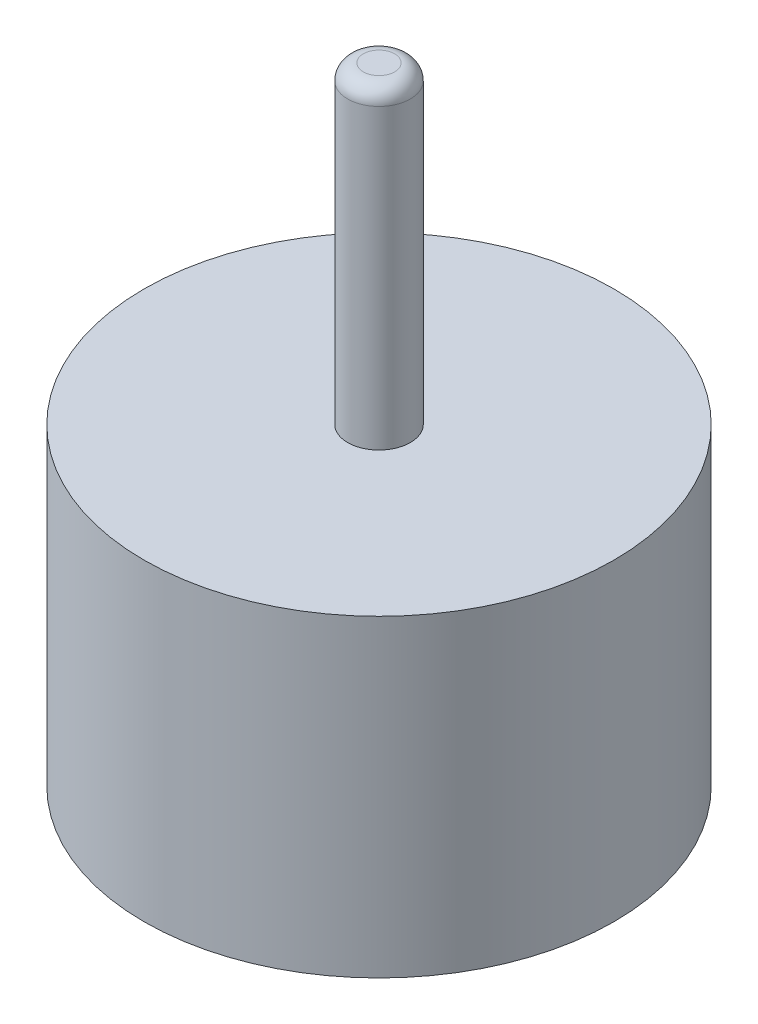
from build123d import *

# Parameters (mm, degrees)
SKETCH_1_R      = 75
EXTRUDE_1_DEPTH = 100
SKETCH_2_R      = 10
EXTRUDE_2_DEPTH = 100
FILLET_1_R      = 5


with BuildPart() as part:
    # 草图1 → 凸台-拉伸1 (new body)
    with BuildSketch(Plane(origin=(0, 0, 0), x_dir=(1, 0, 0), z_dir=(0, 1, 0))):
        Circle(SKETCH_1_R)
    extrude(amount=EXTRUDE_1_DEPTH)

    # 草图2 → 凸台-拉伸2 (add)
    with BuildSketch(Plane(origin=(0, 100, 0), x_dir=(1, 0, 0), z_dir=(0, 1, 0))):
        Circle(SKETCH_2_R)
    extrude(amount=EXTRUDE_2_DEPTH)

    # 圆角1
    fillet_1_edges = [part.edges().sort_by_distance(p)[0] for p in [
        (-10, 200, 0),
    ]]
    fillet(fillet_1_edges, radius=FILLET_1_R)


solid = part.part
